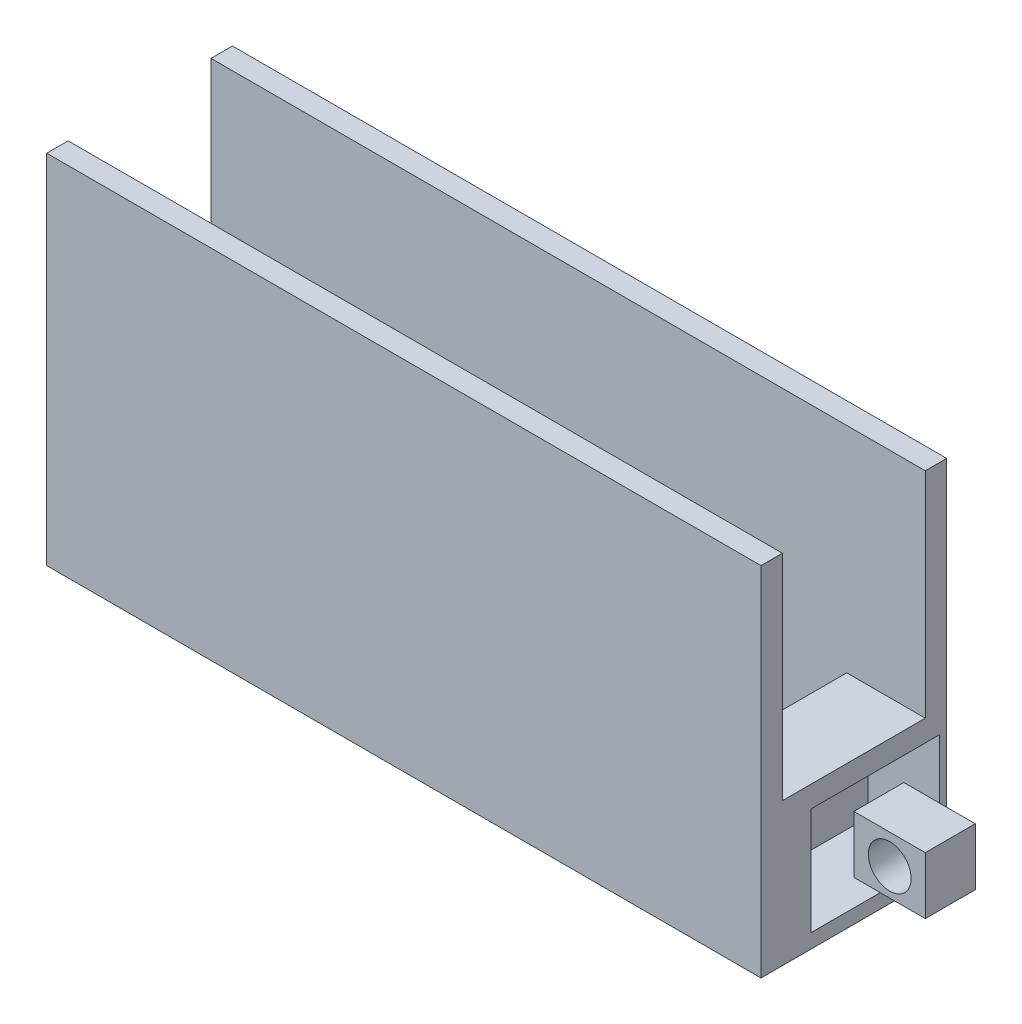
from build123d import *

# Parameters (mm, degrees)
SKETCH19_W           = 10
SKETCH19_H           = 2.6
BOSS_EXTRUDE14_DEPTH = 7
SKETCH20_W           = 10
SKETCH20_H           = 2
CUT_EXTRUDE8_DEPTH   = 5
SKETCH21_W           = 0.7
SKETCH21_H           = 0.8
BOSS_EXTRUDE15_DEPTH = 1
SKETCH22_R           = 0.3
CUT_EXTRUDE9_DEPTH   = 1
SKETCH23_W           = 1.8
SKETCH23_H           = 1.5
CUT_EXTRUDE10_DEPTH  = 1
SKETCH24_W           = 8.8
SKETCH24_H           = 1.8
CUT_EXTRUDE11_DEPTH  = 10
SKETCH25_W           = 2
SKETCH25_H           = 1.8
CUT_EXTRUDE13_DEPTH  = 8.9
SKETCH26_W           = 10
SKETCH26_H           = 2
CUT_EXTRUDE14_DEPTH  = 10


with BuildPart() as part:
    # Sketch19 → Boss-Extrude14 (new body)
    with BuildSketch(Plane(origin=(0, 0, 0), x_dir=(1, 0, 0), z_dir=(0, 1, 0))):
        with Locations((17.528038796, -1.3)):
            Rectangle(SKETCH19_W, SKETCH19_H)
    extrude(amount=BOSS_EXTRUDE14_DEPTH)

    # Sketch20 → Cut-Extrude8 (cut)
    with BuildSketch(Plane(origin=(0, 7, 0), x_dir=(1, 0, 0), z_dir=(0, 1, 0))):
        with Locations((17.528038796, -1.3)):
            Rectangle(SKETCH20_W, SKETCH20_H)
    extrude(amount=-CUT_EXTRUDE8_DEPTH, mode=Mode.SUBTRACT)

    # Sketch21 → Boss-Extrude15 (add)
    with BuildSketch(Plane(origin=(22.528038796, 0, 0), x_dir=(0, 0, -1), z_dir=(1, 0, 0))):
        with Locations((-0.95, 0.97)):
            Rectangle(SKETCH21_W, SKETCH21_H)
    extrude(amount=BOSS_EXTRUDE15_DEPTH)

    # Sketch22 → Cut-Extrude9 (cut)
    with BuildSketch(Plane.XY.offset(1.3)):
        with Locations((23.030317853, 0.955099212)):
            Circle(SKETCH22_R)
    extrude(amount=-CUT_EXTRUDE9_DEPTH, mode=Mode.SUBTRACT)

    # Sketch23 → Cut-Extrude10 (cut)
    with BuildSketch(Plane(origin=(22.528038796, 0, 0), x_dir=(0, 0, -1), z_dir=(1, 0, 0))):
        with Locations((-1, 0.95)):
            Rectangle(SKETCH23_W, SKETCH23_H)
    extrude(amount=-CUT_EXTRUDE10_DEPTH, mode=Mode.SUBTRACT)

    # Sketch24 → Cut-Extrude11 (cut)
    with BuildSketch(Plane(origin=(0, 2, 0), x_dir=(1, 0, 0), z_dir=(0, 1, 0))):
        with Locations((17.028038796, -1.3)):
            Rectangle(SKETCH24_W, SKETCH24_H)
    extrude(amount=-CUT_EXTRUDE11_DEPTH, mode=Mode.SUBTRACT)

    # Sketch25 → Cut-Extrude13 (cut)
    with BuildSketch(Plane.ZY.offset(-12.528038796)):
        with Locations((1.3, 1.1)):
            Rectangle(SKETCH25_W, SKETCH25_H)
    extrude(amount=-CUT_EXTRUDE13_DEPTH, mode=Mode.SUBTRACT)

    # Sketch26 → Cut-Extrude14 (cut)
    with BuildSketch(Plane(origin=(0, 0, 0), x_dir=(-1, 0, 0), z_dir=(0, 0, -1))):
        with Locations((-17.528038796, 6)):
            Rectangle(SKETCH26_W, SKETCH26_H)
    extrude(amount=-CUT_EXTRUDE14_DEPTH, mode=Mode.SUBTRACT)


solid = part.part
